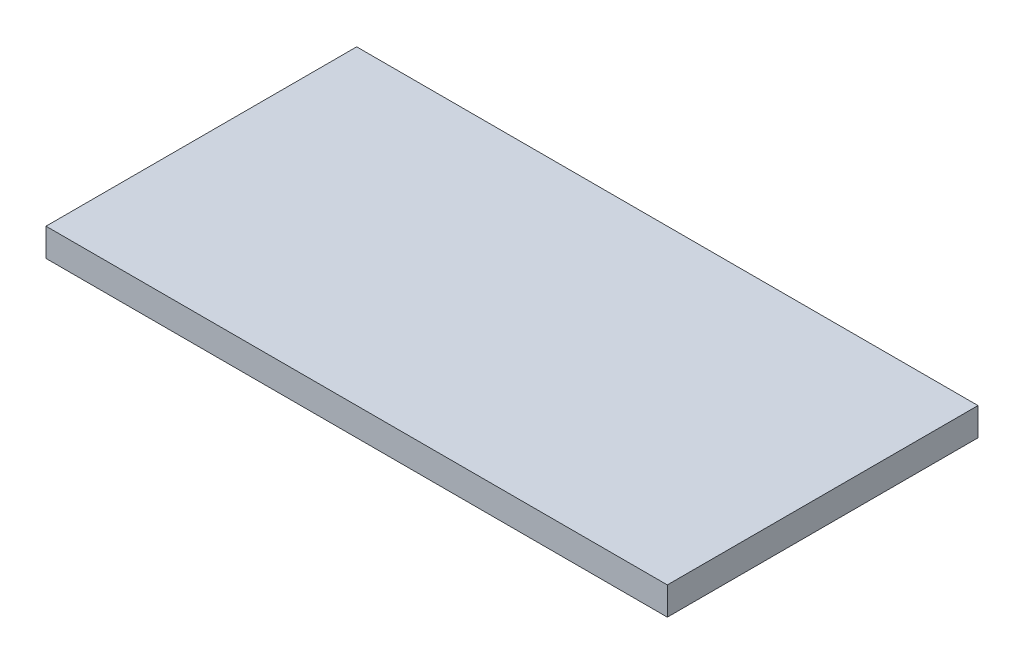
from build123d import *

# Parameters (mm, degrees)
SKETCH1_W           = 80
SKETCH1_H           = 40
BOSS_EXTRUDE1_DEPTH = 3.6


with BuildPart() as part:
    # Sketch1 → Boss-Extrude1 (new body)
    with BuildSketch(Plane(origin=(0, 0, 0), x_dir=(1, 0, 0), z_dir=(0, 1, 0))):
        with Locations((40, -20)):
            Rectangle(SKETCH1_W, SKETCH1_H)
    extrude(amount=BOSS_EXTRUDE1_DEPTH)


solid = part.part
